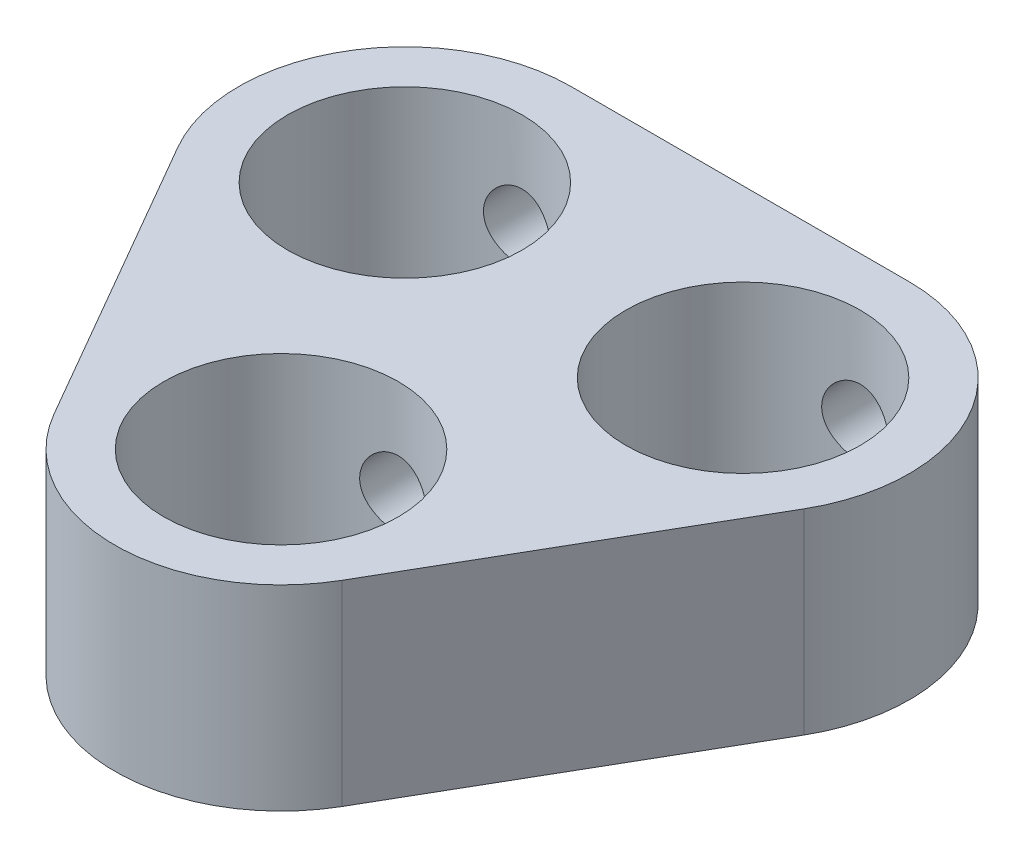
from build123d import *

# Parameters (mm, degrees)
SKETCH1_W                       = 63.925633075
SKETCH1_H                       = 55.87744186
EXTRUDE1_DEPTH                  = 6.35
SKETCH2_OUTSIDE_W               = 82.953
SKETCH2_OUTSIDE_H               = 74.905
SKETCH2_OUTSIDE_R               = 3.8
CUT_EXTRUDE1_DEPTH              = 6.35
F_2_56_TAPPED_HOLE1_D           = 1.778
F_2_56_TAPPED_HOLE1_DEPTH       = 5.588
F_2_56_TAPPED_HOLE1_CBORE_D     = 2.1844
F_2_56_TAPPED_HOLE1_CBORE_DEPTH = 4.318
F_2_56_TAPPED_HOLE1_TIP         = 0.53416509
F_2_56_TAPPED_HOLE2_D           = 1.778
F_2_56_TAPPED_HOLE2_DEPTH       = 13.208
F_2_56_TAPPED_HOLE2_CBORE_D     = 2.1844
F_2_56_TAPPED_HOLE2_CBORE_DEPTH = 11.938
F_2_56_TAPPED_HOLE2_TIP         = 0.53416509


with BuildPart() as part:
    # Sketch1 → Extrude1 (new body)
    with BuildSketch(Plane(origin=(0, 0, 0), x_dir=(1, 0, 0), z_dir=(0, 1, 0))):
        with Locations((1.954560723, 3.334250646)):
            Rectangle(SKETCH1_W, SKETCH1_H)
    extrude(amount=EXTRUDE1_DEPTH)

    # Sketch2 outside → Cut-Extrude1 (cut)
    with BuildSketch(Plane.XZ):
        with Locations((1.9545, -3.3345)):
            Rectangle(SKETCH2_OUTSIDE_W, SKETCH2_OUTSIDE_H)
        with BuildLine():
            Line((-10.146711863, -0.470706825), (-4.665711863, 9.022663651))
            ThreePointArc((-4.665711863, 9.022663651), (0, 11.716413651), (4.665711863, 9.022663651))
            Line((4.665711863, 9.022663651), (10.146711863, -0.470706825))
            ThreePointArc((10.146711863, -0.470706825), (10.146711863, -5.858206825), (5.481, -8.551956825))
            Line((5.481, -8.551956825), (-5.481, -8.551956825))
            ThreePointArc((-5.481, -8.551956825), (-10.146711863, -5.858206825), (-10.146711863, -0.470706825))
        make_face(mode=Mode.SUBTRACT)
        with Locations((0, 6.328913651)):
            Circle(SKETCH2_OUTSIDE_R)
        with Locations((5.481, -3.164456825)):
            Circle(SKETCH2_OUTSIDE_R)
        with Locations((-5.481, -3.164456825)):
            Circle(SKETCH2_OUTSIDE_R)
    extrude(amount=-CUT_EXTRUDE1_DEPTH, mode=Mode.SUBTRACT)

    # #2-56 Tapped Hole1
    with Locations(Plane(origin=(5.481, 3.175, -8.551956825), x_dir=(-1, 0, 0), z_dir=(0, 0, -1))):
        with Locations((0, 0), (10.962, 0)):
            CounterBoreHole(F_2_56_TAPPED_HOLE1_D / 2, F_2_56_TAPPED_HOLE1_CBORE_D / 2, F_2_56_TAPPED_HOLE1_CBORE_DEPTH, depth=F_2_56_TAPPED_HOLE1_DEPTH)
            with Locations((0, 0, -(F_2_56_TAPPED_HOLE1_DEPTH + F_2_56_TAPPED_HOLE1_TIP / 2))):  # 118° drill point
                Cone(0, F_2_56_TAPPED_HOLE1_D / 2, F_2_56_TAPPED_HOLE1_TIP, mode=Mode.SUBTRACT)

    # #2-56 Tapped Hole2
    with Locations(Plane(origin=(0, 3.175, -8.551956825), x_dir=(-1, 0, 0), z_dir=(0, 0, -1))):
        with Locations((0, 0)):
            CounterBoreHole(F_2_56_TAPPED_HOLE2_D / 2, F_2_56_TAPPED_HOLE2_CBORE_D / 2, F_2_56_TAPPED_HOLE2_CBORE_DEPTH, depth=F_2_56_TAPPED_HOLE2_DEPTH)
            with Locations((0, 0, -(F_2_56_TAPPED_HOLE2_DEPTH + F_2_56_TAPPED_HOLE2_TIP / 2))):  # 118° drill point
                Cone(0, F_2_56_TAPPED_HOLE2_D / 2, F_2_56_TAPPED_HOLE2_TIP, mode=Mode.SUBTRACT)


solid = part.part
